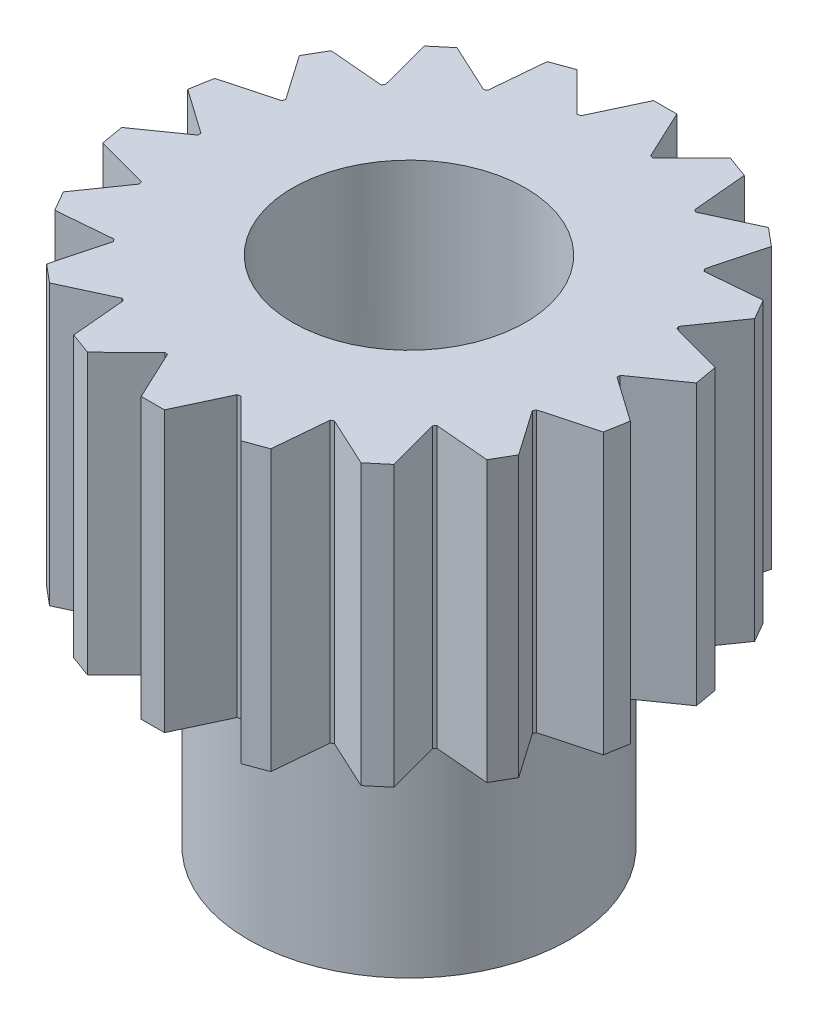
from build123d import *

# Parameters (mm, degrees)
SKETCH1_R           = 2.285
SKETCH1_R_2         = 1.27
BOSS_EXTRUDE1_DEPTH = 3.048
BOSS_EXTRUDE2_DEPTH = 3.048
CIRPATTERN1_COUNT   = 18
SKETCH3_R           = 1.75
SKETCH3_R_2         = 1.27
BOSS_EXTRUDE3_DEPTH = 2.54


with BuildPart() as part:
    # Sketch1 → Boss-Extrude1 (new body)
    with BuildSketch(Plane(origin=(0, 0, 0), x_dir=(1, 0, 0), z_dir=(0, 1, 0))):
        Circle(SKETCH1_R)
        Circle(SKETCH1_R_2, mode=Mode.SUBTRACT)
    extrude(amount=BOSS_EXTRUDE1_DEPTH)

    # Sketch2 → Boss-Extrude2 (add)
    with BuildSketch(Plane(origin=(0, 3.048, 0), x_dir=(1, 0, 0), z_dir=(0, 1, 0))):
        with BuildLine():
            Line((-0.127, 2.792943956), (0.127, 2.792943956))
            Line((0.127, 2.792943956), (0.38, 2.253139456))
            ThreePointArc((0.38, 2.253139456), (0, 2.285), (-0.38, 2.253139456))
            Line((-0.38, 2.253139456), (-0.127, 2.792943956))
        make_face()
    boss_extrude2 = extrude(amount=-BOSS_EXTRUDE2_DEPTH)

    # CirPattern1: Boss-Extrude2 ×18 about axis
    cirpattern1_axis = Axis((0, 0, 0), (0, 1, 0))
    for i in range(1, CIRPATTERN1_COUNT):
        add(boss_extrude2.rotate(cirpattern1_axis, i * 360 / CIRPATTERN1_COUNT))

    # Sketch3 → Boss-Extrude3 (add)
    with BuildSketch(Plane.XZ):
        Circle(SKETCH3_R)
        Circle(SKETCH3_R_2, mode=Mode.SUBTRACT)
    extrude(amount=BOSS_EXTRUDE3_DEPTH)


solid = part.part
